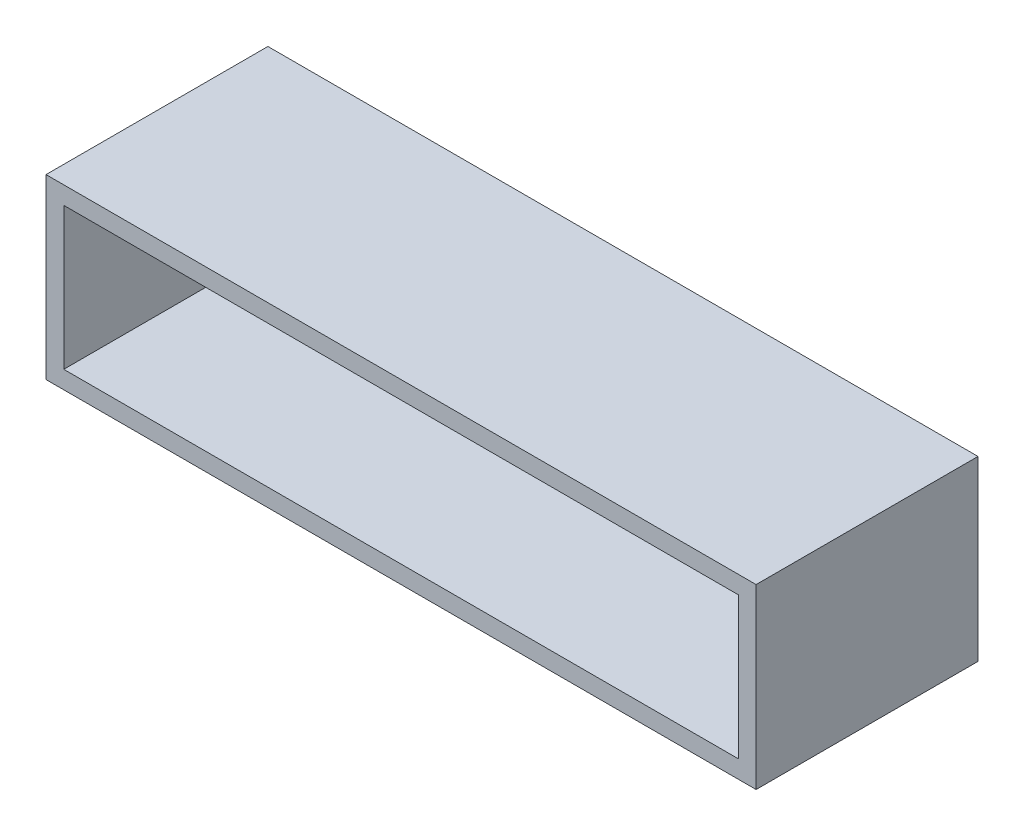
from build123d import *

# Parameters (mm, degrees)
SKETCH1_W           = 80
SKETCH1_H           = 25
BOSS_EXTRUDE1_DEPTH = 20
SKETCH3_W           = 76
SKETCH3_H           = 16
CUT_EXTRUDE1_DEPTH  = 23
SKETCH4_R           = 1
CUT_EXTRUDE2_DEPTH  = 48
SKETCH5_R           = 2.5
CUT_EXTRUDE3_DEPTH  = 48


with BuildPart() as part:
    # Sketch1 → Boss-Extrude1 (new body)
    with BuildSketch(Plane(origin=(0, 0, 0), x_dir=(1, 0, 0), z_dir=(0, 1, 0))):
        with Locations((-4.196598457, -17.578240617)):
            Rectangle(SKETCH1_W, SKETCH1_H)
    extrude(amount=BOSS_EXTRUDE1_DEPTH)

    # Sketch3 → Cut-Extrude1 (cut)
    with BuildSketch(Plane.XY.offset(30.078240617)):
        with Locations((-4.196598457, 10)):
            Rectangle(SKETCH3_W, SKETCH3_H)
    extrude(amount=-CUT_EXTRUDE1_DEPTH, mode=Mode.SUBTRACT)

    # Sketch4 → Cut-Extrude2 (cut)
    with BuildSketch(Plane.XY.offset(7.078240617)):
        with Locations((30.803401543, 10)):
            Circle(SKETCH4_R)
        with Locations((-39.196598457, 10)):
            Circle(SKETCH4_R)
    extrude(amount=-CUT_EXTRUDE2_DEPTH, mode=Mode.SUBTRACT)

    # Sketch5 → Cut-Extrude3 (cut)
    with BuildSketch(Plane.XY.offset(7.078240617)):
        with Locations((-31.696598457, 10)):
            Circle(SKETCH5_R)
        with Locations((23.303401543, 10)):
            Circle(SKETCH5_R)
    extrude(amount=-CUT_EXTRUDE3_DEPTH, mode=Mode.SUBTRACT)


solid = part.part
